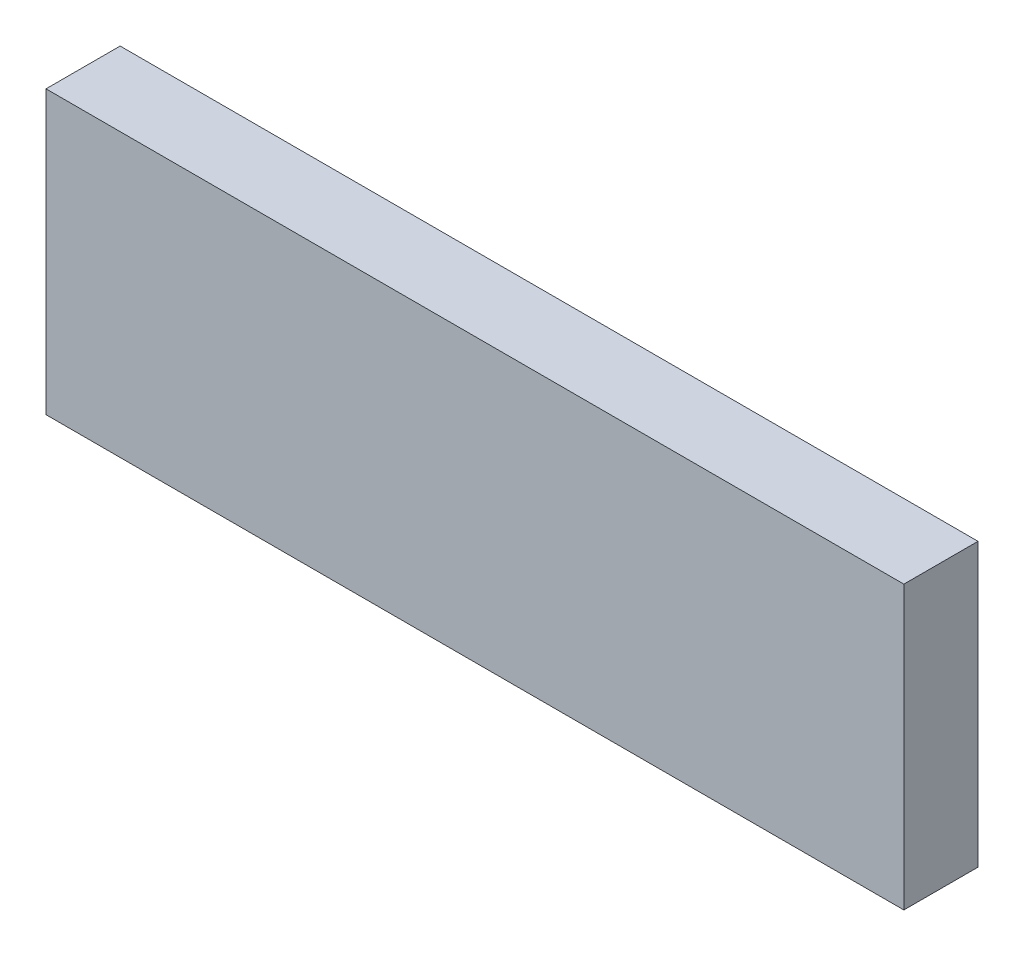
from build123d import *

# Parameters (mm, degrees)
SKETCH1_W           = 224.68
SKETCH1_H           = 73.914
BOSS_EXTRUDE1_DEPTH = 19.419


with BuildPart() as part:
    # Sketch1 → Boss-Extrude1 (new body)
    with BuildSketch(Plane.XY):
        Rectangle(SKETCH1_W, SKETCH1_H)
    extrude(amount=BOSS_EXTRUDE1_DEPTH)


solid = part.part
